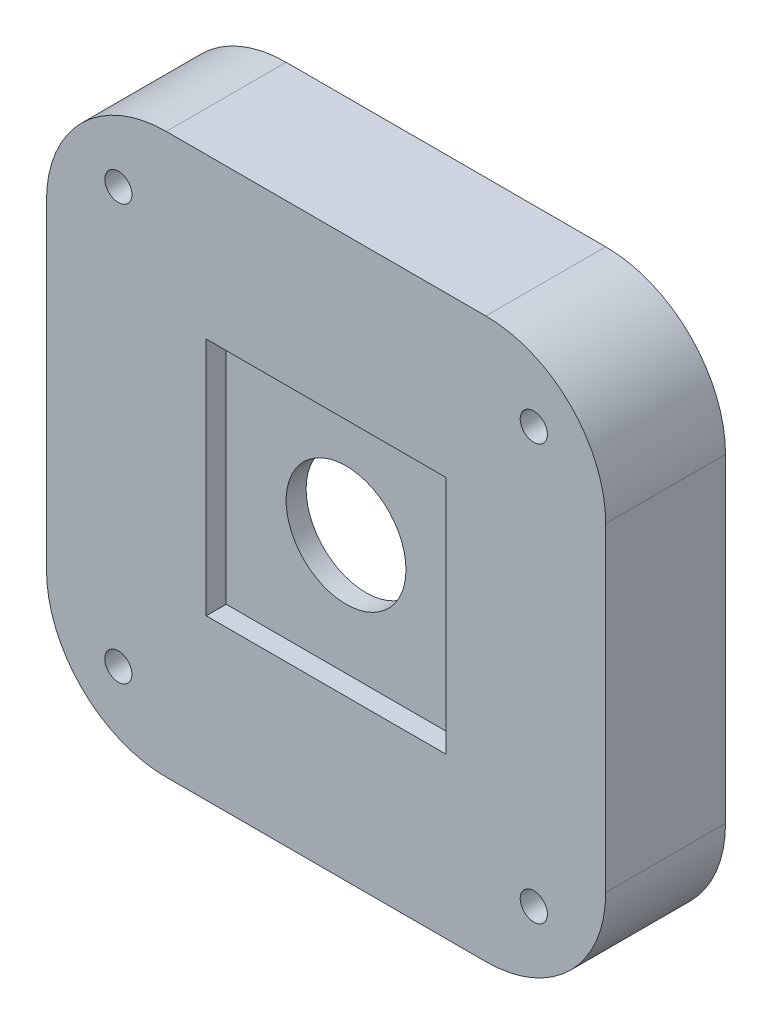
from build123d import *

# Parameters (mm, degrees)
SKETCH1_W            = 70
SKETCH1_H            = 70
BOSS_EXTRUDE1_DEPTH  = 15
FILLET1_R            = 15
M3_CLEARANCE_HOLE1_D = 3.4
SKETCH4_R            = 7.5
CUT_EXTRUDE1_DEPTH   = 16
SKETCH5_W            = 30
SKETCH5_H            = 30
CUT_EXTRUDE2_DEPTH   = 2.5
SKETCH6_W            = 45
SKETCH6_H            = 45
CUT_EXTRUDE3_DEPTH   = 10


with BuildPart() as part:
    # Sketch1 → Boss-Extrude1 (new body)
    with BuildSketch(Plane.XY):
        Rectangle(SKETCH1_W, SKETCH1_H)
    extrude(amount=BOSS_EXTRUDE1_DEPTH)

    # Fillet1
    fillet1_edges = [part.edges().sort_by_distance(p)[0] for p in [
        (-35, 35, 7.5),
        (35, 35, 7.5),
        (35, -35, 7.5),
        (-35, -35, 7.5),
    ]]
    fillet(fillet1_edges, radius=FILLET1_R)

    # M3 Clearance Hole1 (through all)
    with Locations(Plane.XY.offset(15)):
        with Locations((-26, -26), (26, -26), (26, 26), (-26, 26)):
            Hole(M3_CLEARANCE_HOLE1_D / 2)

    # Sketch4 → Cut-Extrude1 (cut, through all)
    with BuildSketch(Plane.XY.offset(15)):
        Circle(SKETCH4_R)
    extrude(amount=-CUT_EXTRUDE1_DEPTH, mode=Mode.SUBTRACT)

    # Sketch5 → Cut-Extrude2 (cut)
    with BuildSketch(Plane.XY.offset(15)):
        Rectangle(SKETCH5_W, SKETCH5_H)
    extrude(amount=-CUT_EXTRUDE2_DEPTH, mode=Mode.SUBTRACT)

    # Sketch6 → Cut-Extrude3 (cut)
    with BuildSketch(Plane(origin=(0, 0, 0), x_dir=(-1, 0, 0), z_dir=(0, 0, -1))):
        Rectangle(SKETCH6_W, SKETCH6_H)
    extrude(amount=-CUT_EXTRUDE3_DEPTH, mode=Mode.SUBTRACT)


solid = part.part
